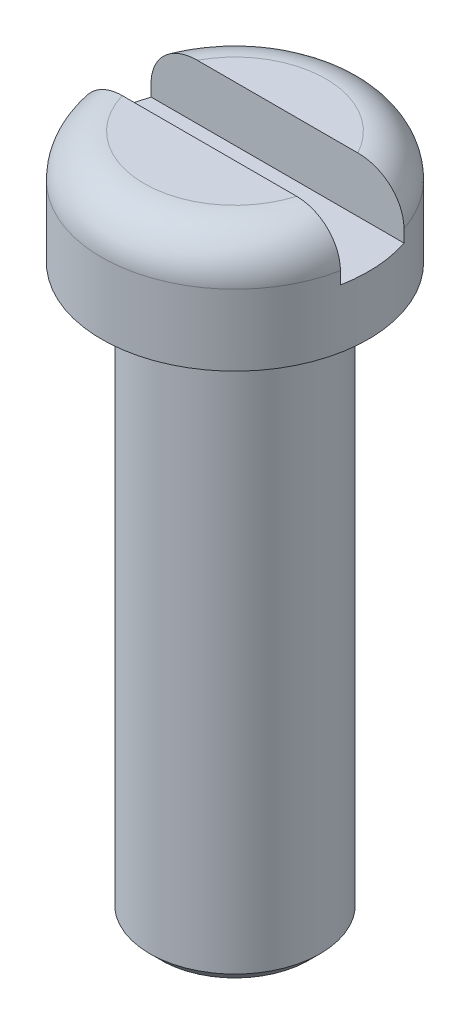
from build123d import *

# Parameters (mm, degrees)
SKETCH2_W               = 1.2
SKETCH2_H               = 2.96832053
CUT_EXTRUDE1_DEPTH      = 3.35
CUT_EXTRUDE1_DEPTH_BACK = 3.35
CHAMFER_1_SIZE          = 0.2


with BuildPart() as part:
    # Sketch1 → Revolve1 (revolve)
    with BuildSketch(Plane(origin=(0, 0, 0), x_dir=(0, 0, -1), z_dir=(1, 0, 0))):
        with BuildLine():
            Line((1.5, -10), (0, -10))
            Line((0, -10), (0, 2))
            Line((0, 2), (1.6, 2))
            ThreePointArc((1.6, 2), (2.130330086, 1.780330086), (2.35, 1.25))
            Line((2.35, 1.25), (2.35, 0))
            Line((2.35, 0), (1.5, 0))
            Line((1.5, 0), (1.5, -10))
        make_face()
    revolve(axis=Axis((0, -26.35, 0), (0, 1, 0)))

    # Sketch2 → Cut-Extrude1 (cut, two sides)
    with BuildSketch(Plane(origin=(0, 0, 0), x_dir=(0, 0, -1), z_dir=(1, 0, 0))) as cut_extrude1_sk:
        with Locations((0.15, 2.515839735)):
            Rectangle(SKETCH2_W, SKETCH2_H)
    extrude(amount=CUT_EXTRUDE1_DEPTH, mode=Mode.SUBTRACT)
    extrude(cut_extrude1_sk.sketch, amount=-CUT_EXTRUDE1_DEPTH_BACK, mode=Mode.SUBTRACT)

    # Фаска1
    chamfer_1_edges = [part.edges().sort_by_distance(p)[0] for p in [
        (0, -10, 1.5),
    ]]
    chamfer(chamfer_1_edges, length=CHAMFER_1_SIZE)


solid = part.part
